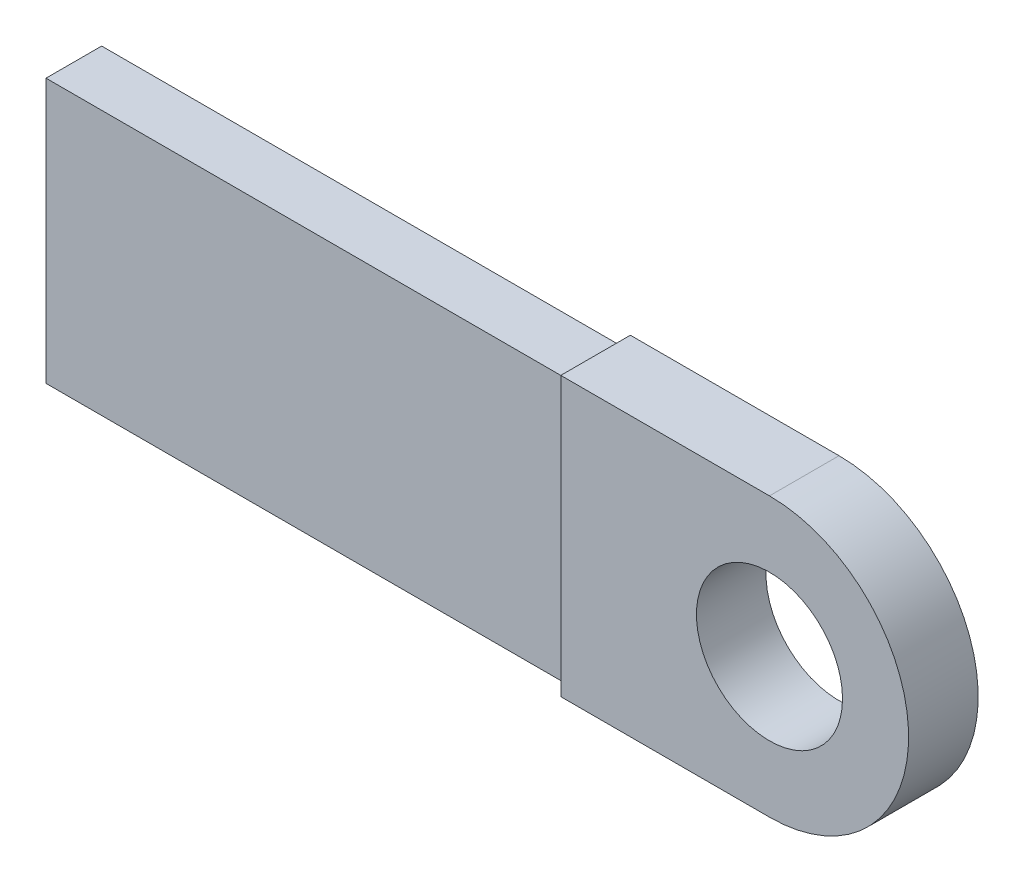
from build123d import *

# Parameters (mm, degrees)
BOSS_EXTRUDE1_DEPTH = 20
SKETCH2_R           = 21
CUT_EXTRUDE1_DEPTH  = 21
SKETCH3_W           = 16
SKETCH3_H           = 76
BOSS_EXTRUDE2_DEPTH = 150


with BuildPart() as part:
    # Sketch1 → Boss-Extrude1 (new body)
    with BuildSketch(Plane.XY):
        with BuildLine():
            Line((0, 80), (0, 0))
            Line((0, 0), (60, 0))
            ThreePointArc((60, 0), (88.284271247, 11.715728753), (100, 40))
            ThreePointArc((100, 40), (88.284271247, 68.284271247), (60, 80))
            Line((60, 80), (0, 80))
        make_face()
    extrude(amount=BOSS_EXTRUDE1_DEPTH)

    # Sketch2 → Cut-Extrude1 (cut, through all)
    with BuildSketch(Plane.XY.offset(20)):
        with Locations((60, 40)):
            Circle(SKETCH2_R)
    extrude(amount=-CUT_EXTRUDE1_DEPTH, mode=Mode.SUBTRACT)

    # Sketch3 → Boss-Extrude2 (add)
    with BuildSketch(Plane.ZY):
        with Locations((10, 40)):
            Rectangle(SKETCH3_W, SKETCH3_H)
    extrude(amount=BOSS_EXTRUDE2_DEPTH)


solid = part.part
